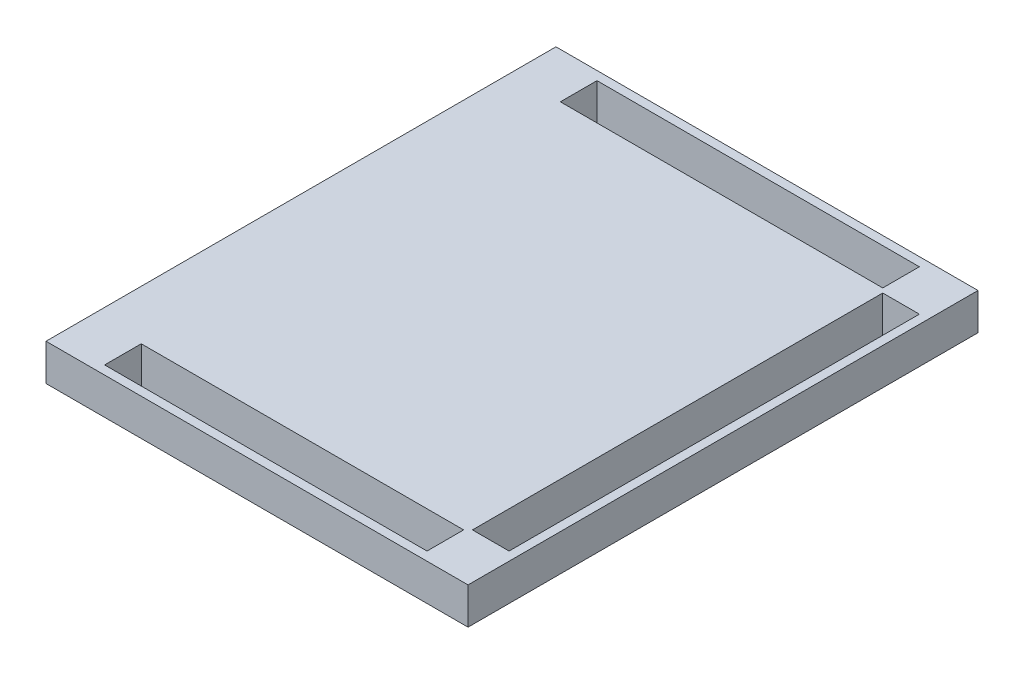
from build123d import *

# Parameters (mm, degrees)
SKETCH1_W           = 288
SKETCH1_H           = 348
BOSS_EXTRUDE1_DEPTH = 25
SKETCH2_W           = 220
SKETCH2_H           = 25
SKETCH2_W_2         = 25
SKETCH2_H_2         = 280
CUT_EXTRUDE5_DEPTH  = 25


with BuildPart() as part:
    # Sketch1 → Boss-Extrude1 (new body)
    with BuildSketch(Plane(origin=(0, 0, 0), x_dir=(1, 0, 0), z_dir=(0, 1, 0))):
        with Locations((111.777306141, 159.011164947)):
            Rectangle(SKETCH1_W, SKETCH1_H)
    extrude(amount=BOSS_EXTRUDE1_DEPTH)

    # Sketch2 → Cut-Extrude5 (cut)
    with BuildSketch(Plane(origin=(0, 0, 0), x_dir=(1, 0, 0), z_dir=(0, 1, 0))):
        with Locations((111.777306141, 314.511164947)):
            Rectangle(SKETCH2_W, SKETCH2_H)
        with Locations((111.777306141, 3.511164947)):
            Rectangle(SKETCH2_W, SKETCH2_H)
        with Locations((237.277306141, 159.011164947)):
            Rectangle(SKETCH2_W_2, SKETCH2_H_2)
    extrude(amount=CUT_EXTRUDE5_DEPTH, mode=Mode.SUBTRACT)


solid = part.part
